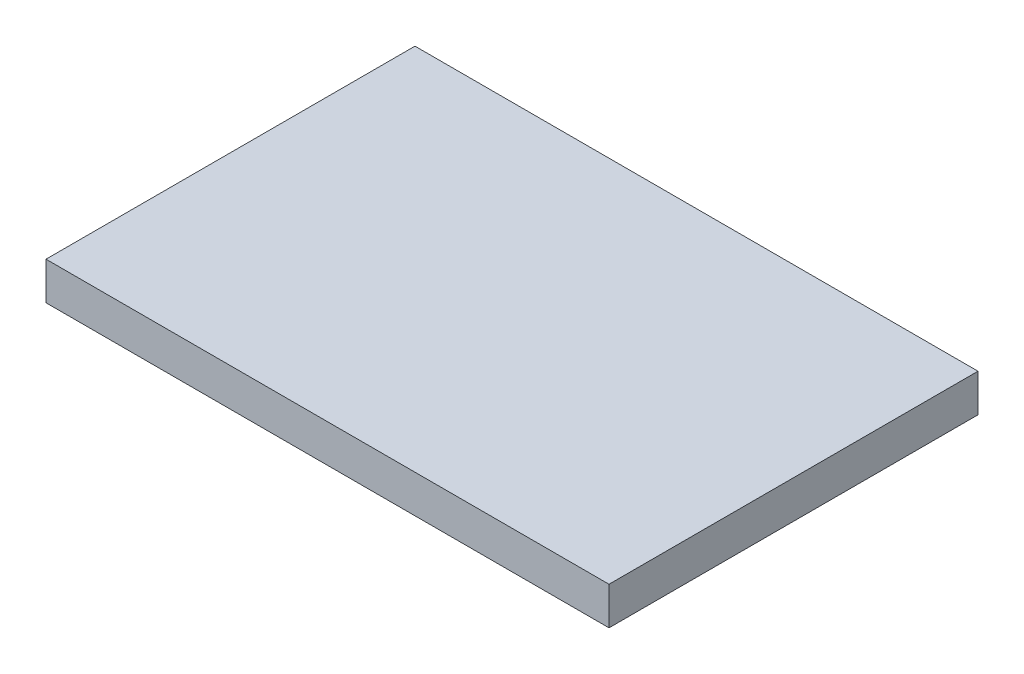
from build123d import *

# Parameters (mm, degrees)
SKETCH1_W           = 15.35
SKETCH1_H           = 10.06
BOSS_EXTRUDE1_DEPTH = 1.03


with BuildPart() as part:
    # Sketch1 → Boss-Extrude1 (new body)
    with BuildSketch(Plane(origin=(0, 0, 0), x_dir=(1, 0, 0), z_dir=(0, 1, 0))):
        Rectangle(SKETCH1_W, SKETCH1_H)
    extrude(amount=BOSS_EXTRUDE1_DEPTH)


solid = part.part
